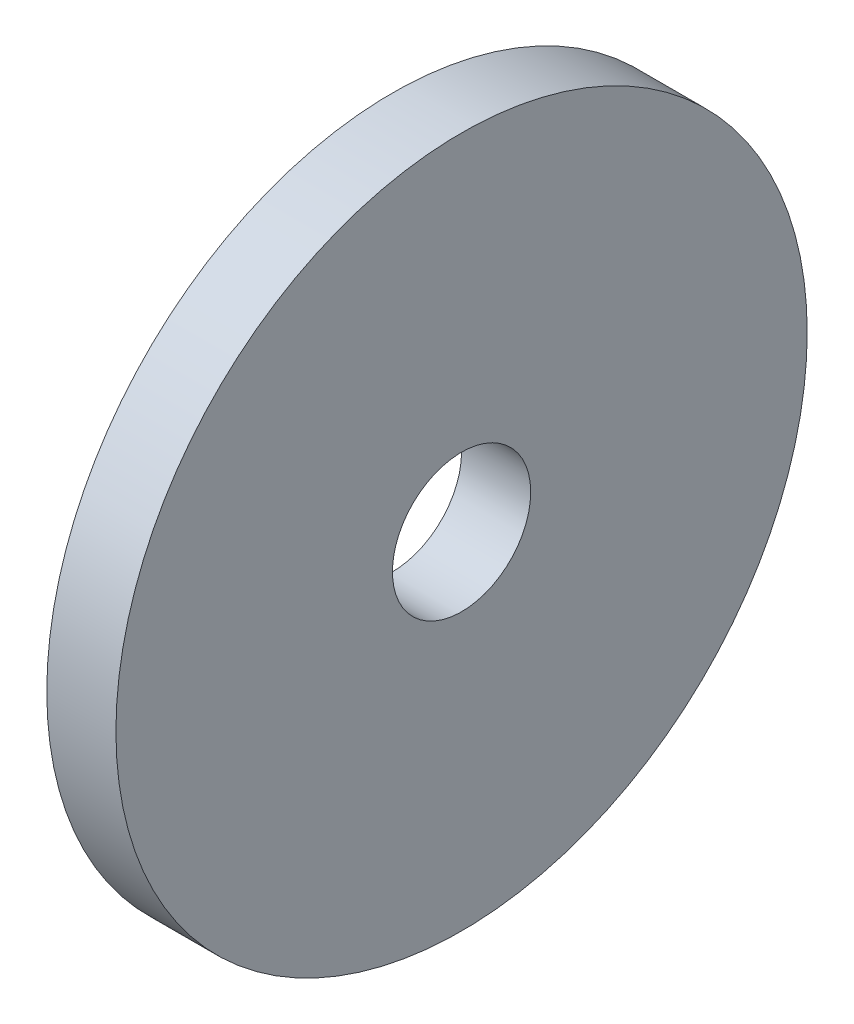
from build123d import *

# Parameters (mm, degrees)
SKETCH1_R           = 10
BOSS_EXTRUDE1_DEPTH = 2
SKETCH2_R           = 2
CUT_EXTRUDE1_DEPTH  = 3


with BuildPart() as part:
    # Sketch1 → Boss-Extrude1 (new body)
    with BuildSketch(Plane(origin=(0, 0, 0), x_dir=(0, 0, -1), z_dir=(1, 0, 0))):
        Circle(SKETCH1_R)
    extrude(amount=BOSS_EXTRUDE1_DEPTH)

    # Sketch2 → Cut-Extrude1 (cut, through all)
    with BuildSketch(Plane(origin=(2, 0, 0), x_dir=(0, 0, -1), z_dir=(1, 0, 0))):
        Circle(SKETCH2_R)
    extrude(amount=-CUT_EXTRUDE1_DEPTH, mode=Mode.SUBTRACT)


solid = part.part
